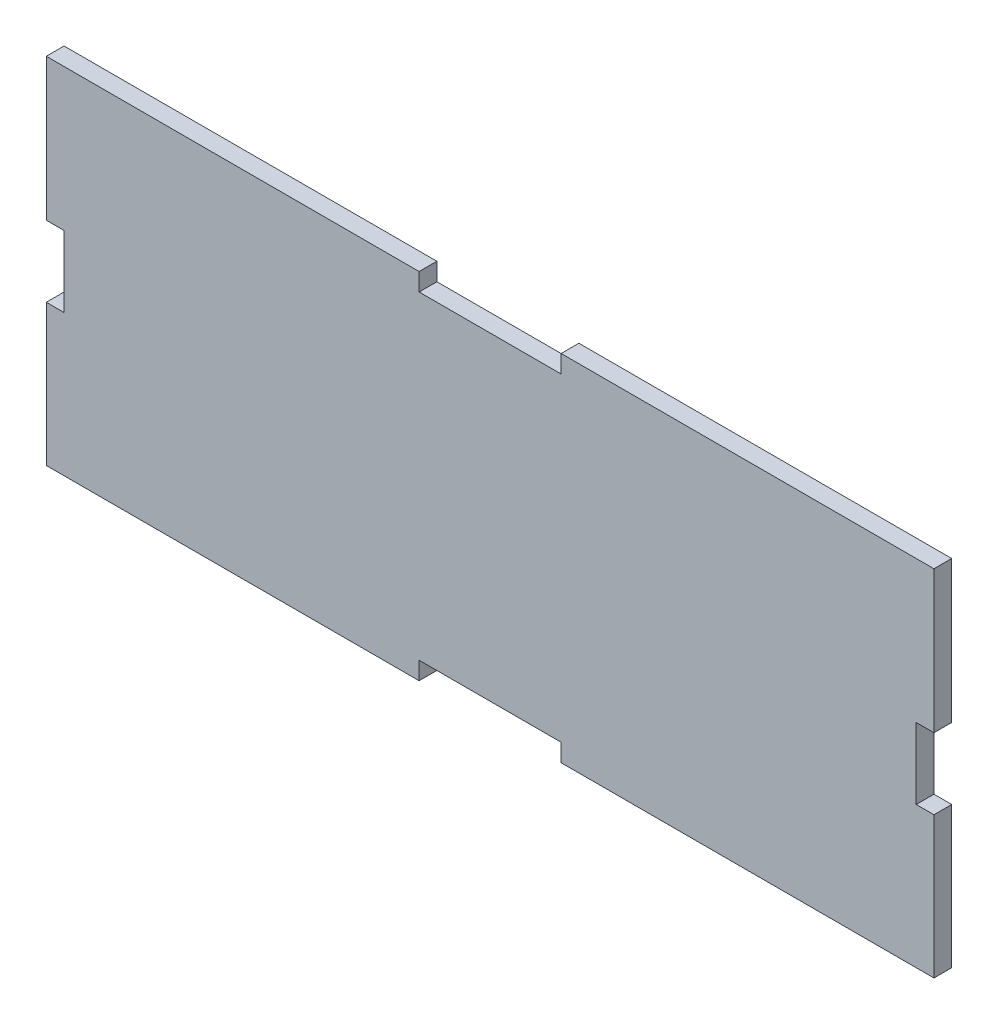
from build123d import *

# Parameters (mm, degrees)
BOSS_EXTRU_1_DEPTH = 5


with BuildPart() as part:
    # Esquisse1 → Boss.-Extru.1 (new body)
    with BuildSketch(Plane.XY):
        Polygon((105, 12.43933918), (105, 17.43933918), (0, 17.43933918), (0, -22.56066082), (5, -22.56066082), (5, -42.56066082), (0, -42.56066082), (0, -82.3798627), (105, -82.3798627), (105, -77.3798627), (145, -77.3798627), (145, -82.3798627), (250, -82.3798627), (250, -42.56066082), (245, -42.56066082), (245, -22.56066082), (250, -22.56066082), (250, 17.43933918), (145, 17.43933918), (145, 12.43933918), align=None)
    extrude(amount=BOSS_EXTRU_1_DEPTH)


solid = part.part
